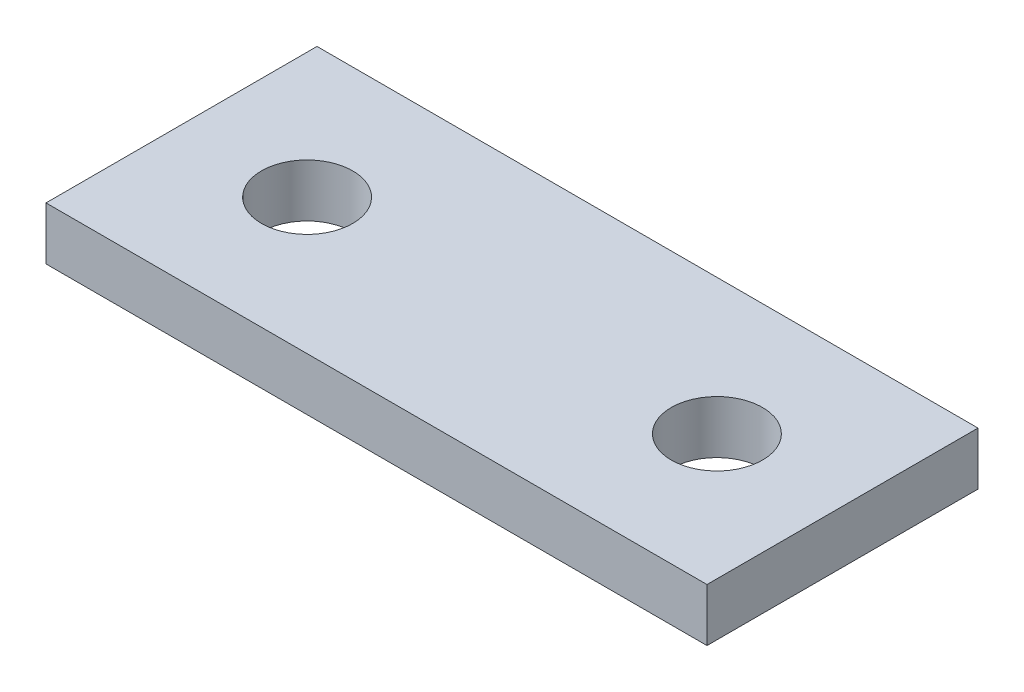
from build123d import *

# Parameters (mm, degrees)
SKETCH1_W           = 25.4
SKETCH1_H           = 10.414
SKETCH1_R           = 1.7526
BOSS_EXTRUDE1_DEPTH = 2.032


with BuildPart() as part:
    # Sketch1 → Boss-Extrude1 (new body)
    with BuildSketch(Plane(origin=(0, 0, 0), x_dir=(1, 0, 0), z_dir=(0, 1, 0))):
        with Locations((1.049586777, -2.678020661)):
            Rectangle(SKETCH1_W, SKETCH1_H)
        with Locations((-6.824413223, -2.678020661)):
            Circle(SKETCH1_R, mode=Mode.SUBTRACT)
        with Locations((8.923586777, -2.678020661)):
            Circle(SKETCH1_R, mode=Mode.SUBTRACT)
    extrude(amount=BOSS_EXTRUDE1_DEPTH)


solid = part.part
